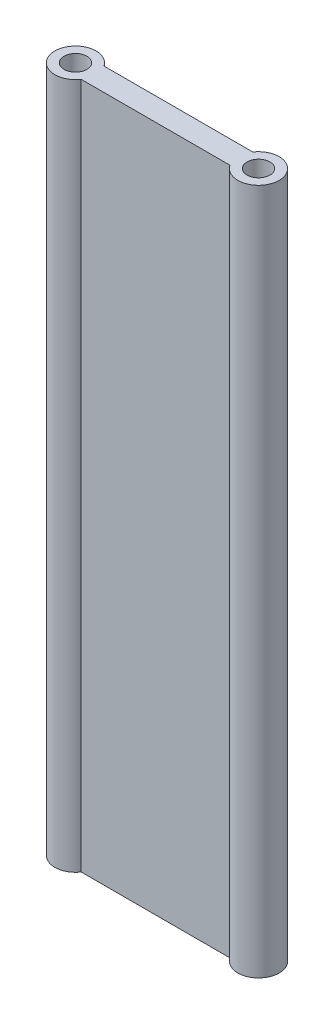
from build123d import *

# Parameters (mm, degrees)
SKETCH1_R           = 3.175
BOSS_EXTRUDE1_DEPTH = 95.25


with BuildPart() as part:
    # Sketch1 → Boss-Extrude1 (new body, symmetric)
    with BuildSketch(Plane(origin=(0, 0, 0), x_dir=(1, 0, 0), z_dir=(0, 1, 0))):
        with BuildLine():
            ThreePointArc((20.648095119, -3.175), (31.115, 0), (20.648095119, 3.175))
            Line((20.648095119, 3.175), (-20.648095119, 3.175))
            ThreePointArc((-20.648095119, 3.175), (-31.115, 0), (-20.648095119, -3.175))
            Line((-20.648095119, -3.175), (20.648095119, -3.175))
        make_face()
        with Locations((-25.4, 0)):
            Circle(SKETCH1_R, mode=Mode.SUBTRACT)
        with Locations((25.4, 0)):
            Circle(SKETCH1_R, mode=Mode.SUBTRACT)
    extrude(amount=BOSS_EXTRUDE1_DEPTH, both=True)


solid = part.part
